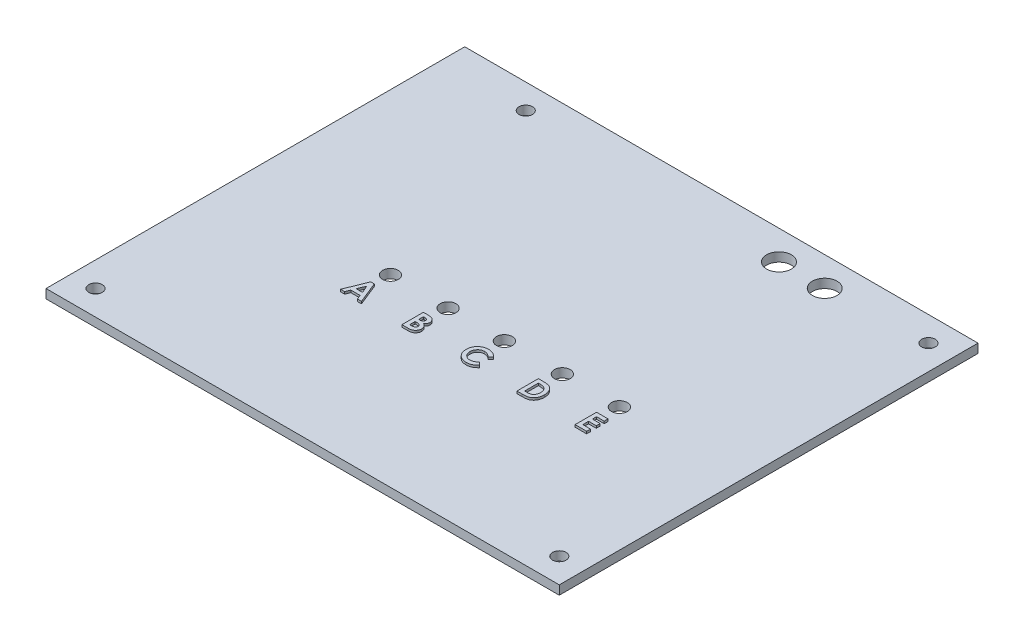
from build123d import *

# Parameters (mm, degrees)
SKETCH1_W           = 114
SKETCH1_H           = 93
BOSS_EXTRUDE1_DEPTH = 2
CUT_EXTRUDE1_REACH  = 4
SKETCH2_R           = 1.5
CUT_EXTRUDE2_REACH  = 4
SKETCH3_R           = 1.75
SKETCH3_R_2         = 2.75
BOSS_EXTRUDE2_DEPTH = 0.5


with BuildPart() as part:
    # Sketch1 → Boss-Extrude1 (new body)
    with BuildSketch(Plane(origin=(0, 0, 0), x_dir=(1, 0, 0), z_dir=(0, 1, 0))):
        with Locations((7.555555556, -17.5)):
            Rectangle(SKETCH1_W, SKETCH1_H)
    extrude(amount=BOSS_EXTRUDE1_DEPTH)

    # Sketch2 → Cut-Extrude1 (cut, up to next)
    with BuildSketch(Plane(origin=(0, 2, 0), x_dir=(1, 0, 0), z_dir=(0, 1, 0)), mode=Mode.PRIVATE) as cut_extrude1_sk1:
        with Locations(Location((-30.385824993, 23.5, 0), (0, 0, 270))):  # turned: the seam where the file's is
            Circle(SKETCH2_R)
    cut_extrude1_tool1 = extrude(cut_extrude1_sk1.sketch, amount=-CUT_EXTRUDE1_REACH, mode=Mode.PRIVATE) & part.part
    add(cut_extrude1_tool1.solids().sort_by_distance((-30.385825, 2, -23.5))[0], mode=Mode.SUBTRACT)
    # Sketch2 → Cut-Extrude1 (cut, up to next)
    with BuildSketch(Plane(origin=(0, 2, 0), x_dir=(1, 0, 0), z_dir=(0, 1, 0)), mode=Mode.PRIVATE) as cut_extrude1_sk2:
        with Locations(Location((59.055555556, 23.5, 0), (0, 0, 270))):  # turned: the seam where the file's is
            Circle(SKETCH2_R)
    cut_extrude1_tool2 = extrude(cut_extrude1_sk2.sketch, amount=-CUT_EXTRUDE1_REACH, mode=Mode.PRIVATE) & part.part
    add(cut_extrude1_tool2.solids().sort_by_distance((59.055556, 2, -23.5))[0], mode=Mode.SUBTRACT)
    # Sketch2 → Cut-Extrude1 (cut, up to next)
    with BuildSketch(Plane(origin=(0, 2, 0), x_dir=(1, 0, 0), z_dir=(0, 1, 0)), mode=Mode.PRIVATE) as cut_extrude1_sk3:
        with Locations(Location((59.055555556, -58.5, 0), (0, 0, 270))):  # turned: the seam where the file's is
            Circle(SKETCH2_R)
    cut_extrude1_tool3 = extrude(cut_extrude1_sk3.sketch, amount=-CUT_EXTRUDE1_REACH, mode=Mode.PRIVATE) & part.part
    add(cut_extrude1_tool3.solids().sort_by_distance((59.055556, 2, 58.5))[0], mode=Mode.SUBTRACT)
    # Sketch2 → Cut-Extrude1 (cut, up to next)
    with BuildSketch(Plane(origin=(0, 2, 0), x_dir=(1, 0, 0), z_dir=(0, 1, 0)), mode=Mode.PRIVATE) as cut_extrude1_sk4:
        with Locations(Location((-43.944444444, -58.5, 0), (0, 0, 270))):  # turned: the seam where the file's is
            Circle(SKETCH2_R)
    cut_extrude1_tool4 = extrude(cut_extrude1_sk4.sketch, amount=-CUT_EXTRUDE1_REACH, mode=Mode.PRIVATE) & part.part
    add(cut_extrude1_tool4.solids().sort_by_distance((-43.944444, 2, 58.5))[0], mode=Mode.SUBTRACT)

    # Sketch3 → Cut-Extrude2 (cut, up to next)
    with BuildSketch(Plane(origin=(0, 2, 0), x_dir=(1, 0, 0), z_dir=(0, 1, 0)), mode=Mode.PRIVATE) as cut_extrude2_sk1:
        with Locations(Location((-13.81104525, -23.125143317, 0), (0, 0, 270))):  # turned: the seam where the file's is
            Circle(SKETCH3_R)
    cut_extrude2_tool1 = extrude(cut_extrude2_sk1.sketch, amount=-CUT_EXTRUDE2_REACH, mode=Mode.PRIVATE) & part.part
    add(cut_extrude2_tool1.solids().sort_by_distance((-13.811045, 2, 23.125143))[0], mode=Mode.SUBTRACT)
    # Sketch3 → Cut-Extrude2 (cut, up to next)
    with BuildSketch(Plane(origin=(0, 2, 0), x_dir=(1, 0, 0), z_dir=(0, 1, 0)), mode=Mode.PRIVATE) as cut_extrude2_sk2:
        with Locations(Location((-1.006512362, -23.134717795, 0), (0, 0, 270))):  # turned: the seam where the file's is
            Circle(SKETCH3_R)
    cut_extrude2_tool2 = extrude(cut_extrude2_sk2.sketch, amount=-CUT_EXTRUDE2_REACH, mode=Mode.PRIVATE) & part.part
    add(cut_extrude2_tool2.solids().sort_by_distance((-1.006512, 2, 23.134718))[0], mode=Mode.SUBTRACT)
    # Sketch3 → Cut-Extrude2 (cut, up to next)
    with BuildSketch(Plane(origin=(0, 2, 0), x_dir=(1, 0, 0), z_dir=(0, 1, 0)), mode=Mode.PRIVATE) as cut_extrude2_sk3:
        with Locations(Location((11.560574266, -23.204080979, 0), (0, 0, 270))):  # turned: the seam where the file's is
            Circle(SKETCH3_R)
    cut_extrude2_tool3 = extrude(cut_extrude2_sk3.sketch, amount=-CUT_EXTRUDE2_REACH, mode=Mode.PRIVATE) & part.part
    add(cut_extrude2_tool3.solids().sort_by_distance((11.560574, 2, 23.204081))[0], mode=Mode.SUBTRACT)
    # Sketch3 → Cut-Extrude2 (cut, up to next)
    with BuildSketch(Plane(origin=(0, 2, 0), x_dir=(1, 0, 0), z_dir=(0, 1, 0)), mode=Mode.PRIVATE) as cut_extrude2_sk4:
        with Locations(Location((24.354447437, -23.121091968, 0), (0, 0, 270))):  # turned: the seam where the file's is
            Circle(SKETCH3_R)
    cut_extrude2_tool4 = extrude(cut_extrude2_sk4.sketch, amount=-CUT_EXTRUDE2_REACH, mode=Mode.PRIVATE) & part.part
    add(cut_extrude2_tool4.solids().sort_by_distance((24.354447, 2, 23.121092))[0], mode=Mode.SUBTRACT)
    # Sketch3 → Cut-Extrude2 (cut, up to next)
    with BuildSketch(Plane(origin=(0, 2, 0), x_dir=(1, 0, 0), z_dir=(0, 1, 0)), mode=Mode.PRIVATE) as cut_extrude2_sk5:
        with Locations(Location((37.027595197, -23.127442101, 0), (0, 0, 270))):  # turned: the seam where the file's is
            Circle(SKETCH3_R)
    cut_extrude2_tool5 = extrude(cut_extrude2_sk5.sketch, amount=-CUT_EXTRUDE2_REACH, mode=Mode.PRIVATE) & part.part
    add(cut_extrude2_tool5.solids().sort_by_distance((37.027595, 2, 23.127442))[0], mode=Mode.SUBTRACT)
    # Sketch3 → Cut-Extrude2 (cut, up to next)
    with BuildSketch(Plane(origin=(0, 2, 0), x_dir=(1, 0, 0), z_dir=(0, 1, 0)), mode=Mode.PRIVATE) as cut_extrude2_sk6:
        with Locations(Location((26.835670283, 22.52, 0), (0, 0, 270))):  # turned: the seam where the file's is
            Circle(SKETCH3_R_2)
    cut_extrude2_tool6 = extrude(cut_extrude2_sk6.sketch, amount=-CUT_EXTRUDE2_REACH, mode=Mode.PRIVATE) & part.part
    add(cut_extrude2_tool6.solids().sort_by_distance((26.83567, 2, -22.52))[0], mode=Mode.SUBTRACT)
    # Sketch3 → Cut-Extrude2 (cut, up to next)
    with BuildSketch(Plane(origin=(0, 2, 0), x_dir=(1, 0, 0), z_dir=(0, 1, 0)), mode=Mode.PRIVATE) as cut_extrude2_sk7:
        with Locations(Location((36.995670283, 22.52, 0), (0, 0, 270))):  # turned: the seam where the file's is
            Circle(SKETCH3_R_2)
    cut_extrude2_tool7 = extrude(cut_extrude2_sk7.sketch, amount=-CUT_EXTRUDE2_REACH, mode=Mode.PRIVATE) & part.part
    add(cut_extrude2_tool7.solids().sort_by_distance((36.99567, 2, -22.52))[0], mode=Mode.SUBTRACT)

    # Sketch4 → Boss-Extrude2 (add)
    with BuildSketch(Plane(origin=(0, 2, 0), x_dir=(1, 0, 0), z_dir=(0, 1, 0))):
        Polygon((-14.162079666, -27.158973615), (-13.369283692, -27.158973615), (-11.445966384, -31.921473615), (-12.35896969, -31.921473615), (-12.729131949, -30.944550538), (-14.804139461, -30.944550538), (-15.174301721, -31.921473615), (-16.086351, -31.921473615), align=None)
        Polygon((-13.766158692, -28.436415021), (-14.479770471, -30.089742846), (-13.052546913, -30.089742846), align=None, mode=Mode.SUBTRACT)
        with BuildLine():
            Line((-2.464379846, -31.921473615), (-2.464379846, -27.158973615))
            Line((-2.464379846, -27.158973615), (-1.701158692, -27.158973615))
            add(Edge.make_bspline(
                [(-1.701158692, -27.158973615), (-1.647728439, -27.158967517), (-1.544341912, -27.158955718), (-1.395182136, -27.16419372), (-1.25684904, -27.170969662), (-1.129782855, -27.178550365), (-1.013767304, -27.191613432), (-0.908978809, -27.205380477), (-0.815208001, -27.221982685), (-0.757234606, -27.23687538), (-0.729959774, -27.243881969)],
                knots=[0, 0, 0, 0, 1.311965854, 2.538629056, 3.664479157, 4.713267157, 5.663616078, 6.530575999, 7.308677837, 8, 8, 8, 8], degree=3))
            add(Edge.make_bspline(
                [(-0.729959774, -27.243881969), (-0.69414515, -27.253764887), (-0.623865361, -27.273158346), (-0.523202274, -27.312324274), (-0.427709295, -27.35585998), (-0.337503018, -27.405526079), (-0.253137345, -27.461922178), (-0.174932893, -27.525495855), (-0.101202988, -27.593695265), (-0.034565609, -27.668421105), (0.025663602, -27.747382798), (0.077991988, -27.830559653), (0.123458648, -27.916679842), (0.159843886, -28.006827129), (0.187259479, -28.100586363), (0.207311129, -28.197557177), (0.220307314, -28.29804641), (0.221535283, -28.36641252), (0.222158616, -28.401116043)],
                knots=[0, 0, 0, 0, 1.099996261, 2.158545794, 3.195537121, 4.207578794, 5.205712374, 6.197378256, 7.190519799, 8.17788031, 9.159561366, 10.129234751, 11.085776129, 12.040971148, 13.00380137, 13.975669004, 14.972423361, 16, 16, 16, 16], degree=3))
            add(Edge.make_bspline(
                [(0.222158616, -28.401116043), (0.220528785, -28.445700961), (0.217320664, -28.533460894), (0.196826968, -28.662364358), (0.158398094, -28.784196659), (0.108114848, -28.901203121), (0.039745353, -29.012947308), (-0.047070683, -29.11937609), (-0.150927123, -29.223766567), (-0.230590746, -29.286341617), (-0.272027081, -29.318889481)],
                knots=[0, 0, 0, 0, 0.986156485, 1.941127874, 2.875419072, 3.804401753, 4.751181392, 5.761612777, 6.835722519, 8, 8, 8, 8], degree=3))
            add(Edge.make_bspline(
                [(-0.272027081, -29.318889481), (-0.238449063, -29.336030768), (-0.17261186, -29.369640089), (-0.079142373, -29.42488378), (0.007400168, -29.483642452), (0.087403796, -29.544733857), (0.159190341, -29.610747747), (0.225723991, -29.677880313), (0.283722321, -29.74997797), (0.335586175, -29.82447102), (0.380665395, -29.902438133), (0.419924424, -29.983747639), (0.453085118, -30.068677308), (0.481166451, -30.156794918), (0.502109517, -30.248403552), (0.515764841, -30.343535973), (0.526220211, -30.441867731), (0.52703354, -30.50884887), (0.527447077, -30.542905406)],
                knots=[0, 0, 0, 0, 1.164658916, 2.283573913, 3.35186032, 4.395461096, 5.390182219, 6.362969632, 7.312859996, 8.245001507, 9.165155236, 10.092416118, 11.032087915, 11.979892451, 12.947605196, 13.931445124, 14.948243989, 16, 16, 16, 16], degree=3))
            add(Edge.make_bspline(
                [(0.527447077, -30.542905406), (0.524763498, -30.607951444), (0.519467465, -30.736319538), (0.480745454, -30.924793382), (0.413613791, -31.10348368), (0.323469811, -31.271680242), (0.212395083, -31.424514052), (0.084690999, -31.558395143), (-0.058356754, -31.671722514), (-0.190335596, -31.748209698), (-0.304486901, -31.799539751), (-0.399036294, -31.831275227), (-0.500580338, -31.860674923), (-0.610979076, -31.881319997), (-0.72823113, -31.900216639), (-0.853479713, -31.911883817), (-0.98649074, -31.919790377), (-1.077848463, -31.920901192), (-1.124926721, -31.921473615)],
                knots=[0, 0, 0, 0, 1.284142165, 2.534249414, 3.780121997, 5.041676246, 6.291546858, 7.49970053, 8.684500223, 9.883330709, 10.50184324, 11.153274765, 11.851151195, 12.587658647, 13.369265475, 14.195992086, 15.070362669, 16, 16, 16, 16], degree=3))
            Line((-1.124926721, -31.921473615), (-2.464379846, -31.921473615))
        make_face()
        with BuildLine():
            Line((-1.609572154, -28.013781307), (-1.609572154, -29.051762077))
            Line((-1.609572154, -29.051762077), (-1.38251386, -29.051762077))
            add(Edge.make_bspline(
                [(-1.38251386, -29.051762077), (-1.351654598, -29.051492972), (-1.29208266, -29.050973482), (-1.206037315, -29.044282634), (-1.12602904, -29.03286763), (-1.052361288, -29.016940829), (-0.98434782, -28.996716113), (-0.922423122, -28.972381424), (-0.866859469, -28.942690459), (-0.802307355, -28.898464456), (-0.734071115, -28.833383913), (-0.674003521, -28.739361585), (-0.638624109, -28.631236264), (-0.634683796, -28.554977916), (-0.632649077, -28.515599216)],
                knots=[0, 0, 0, 0, 1.065314748, 2.056525647, 2.977365736, 3.853934255, 4.656397591, 5.425096493, 6.14721249, 6.826394842, 8.123232004, 9.372140726, 10.643011755, 12, 12, 12, 12], degree=3))
            add(Edge.make_bspline(
                [(-0.632649077, -28.515599216), (-0.634277225, -28.478714521), (-0.637425184, -28.407399445), (-0.673047704, -28.307266727), (-0.728376518, -28.218528645), (-0.79369996, -28.157794685), (-0.855214675, -28.116315181), (-0.907887348, -28.089002694), (-0.965699562, -28.064552835), (-1.0297705, -28.045857877), (-1.099734281, -28.031829839), (-1.175251051, -28.021527924), (-1.256451105, -28.014516003), (-1.312536155, -28.014031459), (-1.341490723, -28.013781307)],
                knots=[0, 0, 0, 0, 1.347982417, 2.606269829, 3.849316587, 5.153353503, 5.842674298, 6.568177932, 7.326619318, 8.142485038, 9.012069166, 9.942760135, 10.937925643, 12, 12, 12, 12], degree=3))
            Line((-1.341490723, -28.013781307), (-1.609572154, -28.013781307))
        make_face(mode=Mode.SUBTRACT)
        with BuildLine():
            Line((-1.609572154, -29.845512077), (-1.609572154, -31.066665923))
            Line((-1.609572154, -31.066665923), (-1.363433331, -31.066665923))
            add(Edge.make_bspline(
                [(-1.363433331, -31.066665923), (-1.314771373, -31.066387919), (-1.221212685, -31.065853422), (-1.087190031, -31.059395423), (-0.965329933, -31.047756019), (-0.855955274, -31.03322516), (-0.758898526, -31.013538119), (-0.674487764, -30.988508569), (-0.601565404, -30.960971705), (-0.540568693, -30.926960409), (-0.490737873, -30.887379694), (-0.445770784, -30.846927252), (-0.409107421, -30.800261539), (-0.380098684, -30.749385785), (-0.354991673, -30.695563778), (-0.339848897, -30.636693791), (-0.328319719, -30.574520587), (-0.327685238, -30.531516726), (-0.327360615, -30.509514481)],
                knots=[0, 0, 0, 0, 1.753078804, 3.370512758, 4.83203934, 6.162291463, 7.344201807, 8.395507345, 9.331626367, 10.147333109, 10.898971645, 11.62040215, 12.321813352, 13.025280112, 13.727906689, 14.453419512, 15.208716525, 16, 16, 16, 16], degree=3))
            add(Edge.make_bspline(
                [(-0.327360615, -30.509514481), (-0.328076501, -30.484354566), (-0.329470853, -30.435349822), (-0.340858549, -30.363724158), (-0.361553711, -30.296856848), (-0.387620278, -30.233038005), (-0.423893291, -30.174552566), (-0.467002527, -30.119376572), (-0.51908949, -30.069378452), (-0.577664318, -30.021534132), (-0.645986055, -29.979643839), (-0.724086757, -29.943296589), (-0.812390708, -29.912940704), (-0.91117144, -29.888771329), (-1.019995905, -29.868259115), (-1.139658403, -29.856011058), (-1.269162343, -29.84690164), (-1.358962482, -29.845985789), (-1.405410495, -29.845512077)],
                knots=[0, 0, 0, 0, 0.845221588, 1.646264278, 2.427170338, 3.19324141, 3.95557735, 4.731569926, 5.540061037, 6.376114724, 7.268642756, 8.224665384, 9.265483498, 10.400594375, 11.639216012, 12.983232105, 14.439614077, 16, 16, 16, 16], degree=3))
            Line((-1.405410495, -29.845512077), (-1.609572154, -29.845512077))
        make_face(mode=Mode.SUBTRACT)
        with BuildLine():
            Line((13.935716308, -27.985160514), (13.308920935, -28.58428912))
            add(Edge.make_bspline(
                [(13.308920935, -28.58428912), (13.255751046, -28.529311365), (13.151893593, -28.421922585), (12.984540153, -28.279749304), (12.810498668, -28.161267111), (12.633154769, -28.061482163), (12.449318553, -27.985987737), (12.261115667, -27.930973678), (12.06734438, -27.897433686), (11.936207426, -27.893596117), (11.87024906, -27.891665923)],
                knots=[0, 0, 0, 0, 1.115251505, 2.178435587, 3.19620269, 4.182487026, 5.141301733, 6.088180966, 7.038406374, 8, 8, 8, 8], degree=3))
            add(Edge.make_bspline(
                [(11.87024906, -27.891665923), (11.81516581, -27.893190844), (11.706465083, -27.896200107), (11.546863931, -27.918260973), (11.394197181, -27.955776436), (11.247942231, -28.007479694), (11.108529441, -28.074380965), (10.975666515, -28.15642847), (10.849681023, -28.252881203), (10.732237158, -28.363240113), (10.624803637, -28.483815516), (10.529879281, -28.612469183), (10.450364907, -28.748906376), (10.385108753, -28.891745359), (10.334276731, -29.041647262), (10.297976282, -29.198511166), (10.276981072, -29.362523882), (10.273847396, -29.474018504), (10.27225477, -29.530683351)],
                knots=[0, 0, 0, 0, 1.035432265, 2.043311493, 3.022114605, 3.98653278, 4.95457646, 5.923598177, 6.917315552, 7.932509744, 8.948865224, 9.949768934, 10.933144597, 11.912367597, 12.897413939, 13.903909035, 14.934704909, 16, 16, 16, 16], degree=3))
            add(Edge.make_bspline(
                [(10.27225477, -29.530683351), (10.272713746, -29.570454705), (10.273618399, -29.648844861), (10.283521421, -29.764805659), (10.299467621, -29.877315048), (10.322545723, -29.986202605), (10.351405118, -30.091562693), (10.385263758, -30.19430425), (10.427738925, -30.293007617), (10.474887, -30.388819171), (10.529719669, -30.479124573), (10.588839401, -30.565238268), (10.652945098, -30.646738137), (10.722451977, -30.723291003), (10.79833826, -30.793700519), (10.878642568, -30.860083982), (10.964719523, -30.920779589), (11.054781088, -30.977310562), (11.149605282, -31.0264195), (11.246619305, -31.07090271), (11.347294085, -31.107029691), (11.450403845, -31.136151333), (11.555580109, -31.16091494), (11.663851596, -31.176162654), (11.77427973, -31.187709569), (11.848910613, -31.188422524), (11.88646751, -31.188781307)],
                knots=[0, 0, 0, 0, 1.103660481, 2.175337485, 3.227646561, 4.255952547, 5.262355991, 6.258840057, 7.255597736, 8.242457506, 9.22035537, 10.185017736, 11.140346927, 12.096287581, 13.051739095, 14.01125915, 14.986044842, 15.97314143, 16.960198552, 17.947847494, 18.933482797, 19.925264591, 20.920966487, 21.929612487, 22.958107872, 24, 24, 24, 24], degree=3))
            add(Edge.make_bspline(
                [(11.88646751, -31.188781307), (11.950170461, -31.18693868), (12.075330194, -31.183318396), (12.259020099, -31.155008291), (12.434058278, -31.108439769), (12.573912946, -31.053445051), (12.683485384, -30.999137052), (12.766901261, -30.948904828), (12.85315978, -30.89271457), (12.94082826, -30.828445598), (13.030892797, -30.756869163), (13.121763544, -30.67641761), (13.21576681, -30.589740092), (13.277347418, -30.527876645), (13.308920935, -30.49615811)],
                knots=[0, 0, 0, 0, 1.404581149, 2.759636711, 4.088442092, 5.392261763, 6.066678138, 6.783632037, 7.538459478, 8.336747902, 9.180226004, 10.074962426, 11.012997595, 12, 12, 12, 12], degree=3))
            Line((13.308920935, -30.49615811), (13.916635779, -31.1344018))
            add(Edge.make_bspline(
                [(13.916635779, -31.1344018), (13.873916697, -31.175645733), (13.790538184, -31.25614507), (13.664764011, -31.370446617), (13.53914813, -31.473159263), (13.41672516, -31.568011027), (13.295489682, -31.652238647), (13.175454556, -31.725926243), (13.05797863, -31.790937479), (12.94062248, -31.846175974), (12.822655855, -31.893079194), (12.70128206, -31.933459787), (12.576130046, -31.967620316), (12.446435439, -31.995183377), (12.313407954, -32.017285231), (12.175802628, -32.032203854), (12.034491948, -32.042233148), (11.938638724, -32.043134363), (11.890283616, -32.043589)],
                knots=[0, 0, 0, 0, 1.244526981, 2.429050516, 3.560637417, 4.644440555, 5.67424972, 6.652764056, 7.595344123, 8.486817594, 9.369275933, 10.254498637, 11.166417451, 12.086725134, 13.032340136, 13.991389299, 14.986715468, 16, 16, 16, 16], degree=3))
            add(Edge.make_bspline(
                [(11.890283616, -32.043589), (11.801461271, -32.041324741), (11.627660632, -32.036894216), (11.372960326, -32.004067026), (11.131001873, -31.949032821), (10.901196633, -31.871199275), (10.683617678, -31.771770568), (10.478320672, -31.649875641), (10.285636508, -31.505838351), (10.107121694, -31.341346955), (9.945646549, -31.159680016), (9.802921221, -30.964619563), (9.684858824, -30.755206944), (9.586829072, -30.534535853), (9.510171095, -30.301599282), (9.456216875, -30.056145264), (9.422943701, -29.798410801), (9.419303568, -29.622372221), (9.417447077, -29.532591404)],
                knots=[0, 0, 0, 0, 1.078019885, 2.10938526, 3.111377082, 4.085535484, 5.04941344, 6.010039228, 6.978205633, 7.964457913, 8.951525778, 9.924444315, 10.892603023, 11.863865945, 12.85144698, 13.863884204, 14.910567087, 16, 16, 16, 16], degree=3))
            add(Edge.make_bspline(
                [(9.417447077, -29.532591404), (9.41823154, -29.47403712), (9.419786155, -29.357996842), (9.436125295, -29.187060111), (9.458903007, -29.020427374), (9.495037776, -28.859828831), (9.538594677, -28.703100924), (9.592763405, -28.551947102), (9.657457446, -28.405932933), (9.730591558, -28.264813981), (9.813327448, -28.129514727), (9.90575252, -28.001197605), (10.005487392, -27.878872028), (10.11492853, -27.764160875), (10.232485612, -27.656056958), (10.358689394, -27.555146113), (10.492780824, -27.459981164), (10.635122836, -27.373016186), (10.782950106, -27.294351741), (10.934398142, -27.22496634), (11.089094854, -27.166976124), (11.24638617, -27.118875378), (11.406936644, -27.082971573), (11.569600308, -27.05579355), (11.735761233, -27.040600862), (11.8473239, -27.038113722), (11.903639986, -27.036858231)],
                knots=[0, 0, 0, 0, 1.071919942, 2.124283339, 3.142214191, 4.149696895, 5.136002878, 6.119640489, 7.086990633, 8.058538607, 9.028339693, 9.988281803, 10.952401235, 11.916291999, 12.888973767, 13.874849856, 14.873389453, 15.898127285, 16.927174885, 17.938320013, 18.946391617, 19.950418109, 20.947802303, 21.956882652, 22.968648068, 24, 24, 24, 24], degree=3))
            add(Edge.make_bspline(
                [(11.903639986, -27.036858231), (11.951683381, -27.03757791), (12.047270655, -27.039009785), (12.189616145, -27.050946026), (12.330823223, -27.069691771), (12.470386323, -27.097975109), (12.609303744, -27.131551005), (12.745749955, -27.17551401), (12.88187747, -27.224519063), (13.015551329, -27.283094599), (13.146958122, -27.347035086), (13.273019438, -27.419577892), (13.395851835, -27.496258811), (13.512733421, -27.581616158), (13.625853639, -27.672553863), (13.734620974, -27.769496201), (13.838080929, -27.874059484), (13.903006653, -27.947939617), (13.935716308, -27.985160514)],
                knots=[0, 0, 0, 0, 0.996412454, 1.982464992, 2.961075852, 3.949442424, 4.934965278, 5.923860011, 6.921385422, 7.934793307, 8.949617135, 9.951082467, 10.950285876, 11.951772932, 12.951063433, 13.960125323, 14.972308753, 16, 16, 16, 16], degree=3))
        make_face()
        with BuildLine():
            Line((23.069947077, -27.158973615), (24.147042931, -27.158973615))
            add(Edge.make_bspline(
                [(24.147042931, -27.158973615), (24.231014941, -27.159560608), (24.393333787, -27.160695273), (24.628501682, -27.17348021), (24.8471779, -27.193142537), (25.049503401, -27.220191631), (25.235063388, -27.255984989), (25.403618583, -27.300880741), (25.555734699, -27.352705418), (25.693079657, -27.413687667), (25.818462393, -27.484786914), (25.937517303, -27.563985765), (26.050010625, -27.654185509), (26.157521025, -27.753646011), (26.258661057, -27.86418687), (26.355115067, -27.983977131), (26.444521422, -28.114753916), (26.529582684, -28.253381611), (26.606509276, -28.400447707), (26.673607524, -28.554700407), (26.729816133, -28.715147039), (26.775488539, -28.881958597), (26.811894717, -29.054581316), (26.837367386, -29.233363534), (26.853114844, -29.418139728), (26.854712292, -29.543371627), (26.855524, -29.607005466)],
                knots=[0, 0, 0, 0, 1.44355588, 2.790409838, 4.047694926, 5.217575253, 6.298404546, 7.294384826, 8.214239204, 9.058592145, 9.873746385, 10.689560431, 11.514393297, 12.350027578, 13.205127629, 14.088021785, 14.991911688, 15.926770944, 16.882954281, 17.842803888, 18.816321264, 19.80318086, 20.814351908, 21.847355356, 22.906180909, 24, 24, 24, 24], degree=3))
            add(Edge.make_bspline(
                [(26.855524, -29.607005466), (26.85339851, -29.696796955), (26.849214359, -29.873556756), (26.813969405, -30.132949727), (26.75696638, -30.381603762), (26.67681495, -30.617573792), (26.577448633, -30.838758469), (26.45874444, -31.041257293), (26.322442851, -31.223983355), (26.170131788, -31.386026827), (26.005216002, -31.525305387), (25.833835245, -31.644587282), (25.654319956, -31.738651009), (25.496141898, -31.798301479), (25.358981788, -31.83539891), (25.238556696, -31.857323849), (25.101766078, -31.87743034), (24.947334482, -31.892968204), (24.775939364, -31.906824161), (24.586897542, -31.914352948), (24.38082108, -31.920608253), (24.237681492, -31.921177603), (24.16326138, -31.921473615)],
                knots=[0, 0, 0, 0, 1.315458931, 2.589557908, 3.828601765, 5.048913369, 6.235739168, 7.376350998, 8.481830359, 9.569842114, 10.627874879, 11.640079404, 12.624025415, 13.590060155, 14.111227486, 14.704434459, 15.382649715, 16.137166398, 16.978595427, 17.902333227, 18.909396075, 20, 20, 20, 20], degree=3))
            Line((24.16326138, -31.921473615), (23.069947077, -31.921473615))
            Line((23.069947077, -31.921473615), (23.069947077, -27.158973615))
        make_face()
        with BuildLine():
            Line((23.92475477, -28.013781307), (23.92475477, -31.066665923))
            Line((23.92475477, -31.066665923), (24.371239145, -31.066665923))
            add(Edge.make_bspline(
                [(24.371239145, -31.066665923), (24.424363928, -31.066568576), (24.526540573, -31.066381346), (24.674060518, -31.057463424), (24.810479063, -31.048512289), (24.935420679, -31.031522736), (25.049794652, -31.012597569), (25.152029783, -30.986260607), (25.244233583, -30.958595861), (25.3252798, -30.923375209), (25.399511531, -30.883732022), (25.468241635, -30.837285433), (25.534585428, -30.785708247), (25.59730256, -30.727483506), (25.6566304, -30.663382215), (25.712217926, -30.593074088), (25.764807086, -30.516773639), (25.813048014, -30.434077447), (25.857130833, -30.345858802), (25.896237233, -30.252972232), (25.92866221, -30.15464419), (25.955611865, -30.051795146), (25.974870449, -29.943529682), (25.990803254, -29.830649706), (25.99901708, -29.712707995), (26.000144376, -29.632456514), (26.000716308, -29.591741043)],
                knots=[0, 0, 0, 0, 1.50275155, 2.890291501, 4.180787663, 5.369391935, 6.45668281, 7.458360028, 8.354766181, 9.177074746, 9.954075863, 10.732690366, 11.5210699, 12.329727389, 13.151100085, 13.990027547, 14.863562427, 15.770965086, 16.696477834, 17.652329173, 18.619756807, 19.62365428, 20.657822005, 21.729286259, 22.847956731, 24, 24, 24, 24], degree=3))
            add(Edge.make_bspline(
                [(26.000716308, -29.591741043), (25.999577213, -29.529348433), (25.997356067, -29.407687678), (25.975935813, -29.230486132), (25.941067725, -29.063624331), (25.891314324, -28.907721544), (25.828598619, -28.7623396), (25.750095295, -28.628710195), (25.659182832, -28.504588537), (25.587291737, -28.43177479), (25.551369854, -28.395391884)],
                knots=[0, 0, 0, 0, 1.13821349, 2.219428113, 3.251817212, 4.244760574, 5.201143372, 6.134805572, 7.068016741, 8, 8, 8, 8], degree=3))
            add(Edge.make_bspline(
                [(25.551369854, -28.395391884), (25.515947475, -28.36438873), (25.443601278, -28.301068298), (25.31658513, -28.225194227), (25.176619913, -28.158531419), (25.020503643, -28.105675246), (24.849745114, -28.063874332), (24.663327285, -28.035045263), (24.462248464, -28.016520009), (24.322945742, -28.014713766), (24.251031813, -28.013781307)],
                knots=[0, 0, 0, 0, 0.813307809, 1.661089106, 2.549956539, 3.493439533, 4.508053171, 5.589449661, 6.755572447, 8, 8, 8, 8], degree=3))
            Line((24.251031813, -28.013781307), (23.92475477, -28.013781307))
        make_face(mode=Mode.SUBTRACT)
        Polygon((35.98975477, -27.158973615), (38.554177846, -27.158973615), (38.554177846, -28.013781307), (36.844562462, -28.013781307), (36.844562462, -28.929646692), (38.554177846, -28.929646692), (38.554177846, -29.784454384), (36.844562462, -29.784454384), (36.844562462, -31.066665923), (38.554177846, -31.066665923), (38.554177846, -31.921473615), (35.98975477, -31.921473615), align=None)
    extrude(amount=BOSS_EXTRUDE2_DEPTH)


solid = part.part
